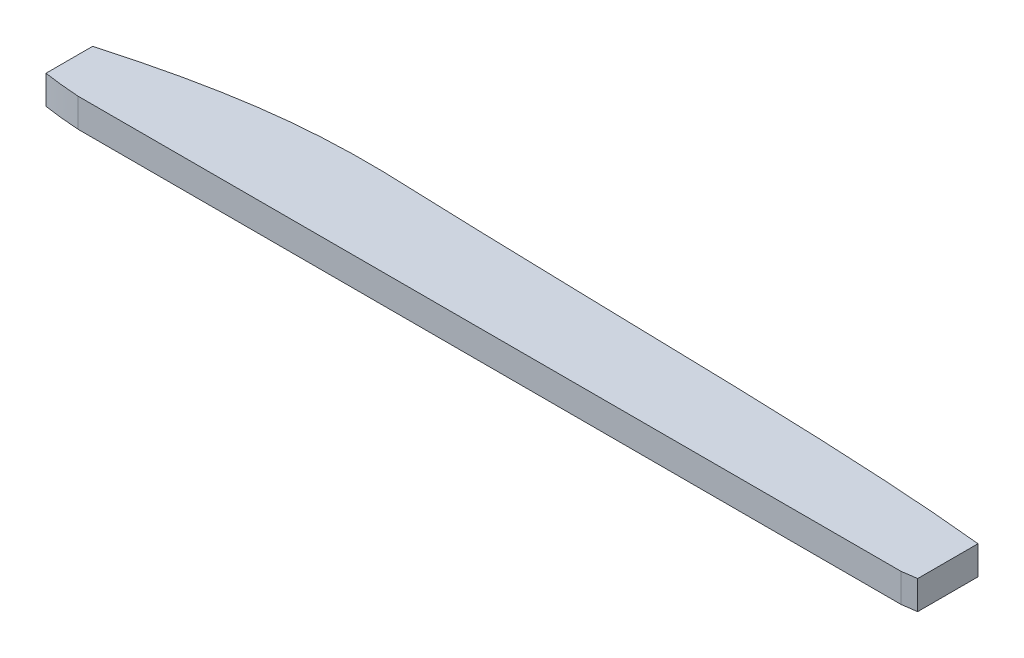
from build123d import *

# Parameters (mm, degrees)
SKETCH1_W           = 304.8
SKETCH1_H           = 76.2
BOSS_EXTRUDE1_DEPTH = 3.175
CUT_EXTRUDE3_DEPTH  = 0.254
CUT_EXTRUDE5_DEPTH  = 0.254
SKETCH2_3_OUTSIDE_W = 369.64
SKETCH2_3_OUTSIDE_H = 141.04
CUT_EXTRUDE7_DEPTH  = 315.196691105


with BuildPart() as part:
    # Sketch1 → Boss-Extrude1 (new body)
    with BuildSketch(Plane(origin=(0, 0, 0), x_dir=(1, 0, 0), z_dir=(0, 1, 0))):
        with Locations((-152.4, 38.1)):
            Rectangle(SKETCH1_W, SKETCH1_H)
    extrude(amount=BOSS_EXTRUDE1_DEPTH)

    # Sketch2 → Cut-Extrude3 (cut)
    with BuildSketch(Plane(origin=(0, 3.175, 0), x_dir=(1, 0, 0), z_dir=(0, 1, 0))):
        with BuildLine():
            Line((-304.8, 5.132354223), (-304.8, 0.390438323))
            add(Edge.make_bspline(
                [(-304.8, 0.390438323), (-303.821243343, 0.22923291), (-302.632591032, 0.100235841), (-301.136713645, 0)],
                knots=[0.767987957, 0.767987957, 0.767987957, 0.767987957, 1, 1, 1, 1], degree=3))
            Line((-301.136713645, 0), (-217.379871236, 0))
            add(Edge.make_bspline(
                [(-215.9, 0.210253502), (-216.602591478, 0.075926224), (-217.379871236, 0)],
                knots=[0.882956558, 0.882956558, 0.882956558, 1, 1, 1], degree=2))
            Line((-215.9, 0.210253502), (-215.9, 6.35))
            add(Edge.make_bspline(
                [(-304.8, 5.132354223), (-295.056068779, 7.913424716), (-284.63514545, 9.175759011), (-256.65451685, 7.910717471), (-231.983718042, 8.039058457), (-215.9, 6.35)],
                knots=[0.033341876, 0.033341876, 0.033341876, 0.033341876, 0.196819423, 0.285044024, 0.915587883, 0.915587883, 0.915587883, 0.915587883], degree=3))
        make_face()
        with BuildLine():
            Line((-304.748193138, 14.319973849), (-304.748193138, 9.578057948))
            add(Edge.make_bspline(
                [(-304.748193138, 9.578057948), (-303.76943648, 9.416852535), (-302.58078417, 9.287855466), (-301.084906782, 9.187619625)],
                knots=[0.767987957, 0.767987957, 0.767987957, 0.767987957, 1, 1, 1, 1], degree=3))
            Line((-301.084906782, 9.187619625), (-217.328064374, 9.187619625))
            add(Edge.make_bspline(
                [(-215.848193138, 9.397873128), (-216.550784616, 9.263545849), (-217.328064374, 9.187619625)],
                knots=[0.882956558, 0.882956558, 0.882956558, 1, 1, 1], degree=2))
            Line((-215.848193138, 9.397873128), (-215.848193138, 15.537619625))
            add(Edge.make_bspline(
                [(-304.748193138, 14.319973849), (-295.004261916, 17.101044341), (-284.583338588, 18.363378636), (-256.602709988, 17.098337097), (-231.93191118, 17.226678082), (-215.848193138, 15.537619625)],
                knots=[0.033341876, 0.033341876, 0.033341876, 0.033341876, 0.196819423, 0.285044024, 0.915587883, 0.915587883, 0.915587883, 0.915587883], degree=3))
        make_face()
        with BuildLine():
            Line((-304.77561062, 23.435546339), (-304.77561062, 18.693630439))
            add(Edge.make_bspline(
                [(-304.77561062, 18.693630439), (-303.796853962, 18.532425025), (-302.608201652, 18.403427957), (-301.112324264, 18.303192116)],
                knots=[0.767987957, 0.767987957, 0.767987957, 0.767987957, 1, 1, 1, 1], degree=3))
            Line((-301.112324264, 18.303192116), (-217.355481855, 18.303192116))
            add(Edge.make_bspline(
                [(-215.87561062, 18.513445618), (-216.578202097, 18.37911834), (-217.355481855, 18.303192116)],
                knots=[0.882956558, 0.882956558, 0.882956558, 1, 1, 1], degree=2))
            Line((-215.87561062, 18.513445618), (-215.87561062, 24.653192116))
            add(Edge.make_bspline(
                [(-304.77561062, 23.435546339), (-295.031679398, 26.216616832), (-284.61075607, 27.478951126), (-256.63012747, 26.213909587), (-231.959328661, 26.342250572), (-215.87561062, 24.653192116)],
                knots=[0.033341876, 0.033341876, 0.033341876, 0.033341876, 0.196819423, 0.285044024, 0.915587883, 0.915587883, 0.915587883, 0.915587883], degree=3))
        make_face()
        with BuildLine():
            Line((-304.723803757, 32.623165964), (-304.723803757, 27.881250064))
            add(Edge.make_bspline(
                [(-304.723803757, 27.881250064), (-303.7450471, 27.720044651), (-302.55639479, 27.591047582), (-301.060517402, 27.490811741)],
                knots=[0.767987957, 0.767987957, 0.767987957, 0.767987957, 1, 1, 1, 1], degree=3))
            Line((-301.060517402, 27.490811741), (-217.303674993, 27.490811741))
            add(Edge.make_bspline(
                [(-215.823803757, 27.701065244), (-216.526395235, 27.566737965), (-217.303674993, 27.490811741)],
                knots=[0.882956558, 0.882956558, 0.882956558, 1, 1, 1], degree=2))
            Line((-215.823803757, 27.701065244), (-215.823803757, 33.840811741))
            add(Edge.make_bspline(
                [(-304.723803757, 32.623165964), (-294.979872536, 35.404236457), (-284.558949208, 36.666570752), (-256.578320608, 35.401529213), (-231.907521799, 35.529870198), (-215.823803757, 33.840811741)],
                knots=[0.033341876, 0.033341876, 0.033341876, 0.033341876, 0.196819423, 0.285044024, 0.915587883, 0.915587883, 0.915587883, 0.915587883], degree=3))
        make_face()
        with BuildLine():
            Line((-304.692120731, 41.752034592), (-304.692120731, 37.010118692))
            add(Edge.make_bspline(
                [(-304.692120731, 37.010118692), (-303.713364073, 36.848913278), (-302.524711763, 36.71991621), (-301.028834375, 36.619680369)],
                knots=[0.767987957, 0.767987957, 0.767987957, 0.767987957, 1, 1, 1, 1], degree=3))
            Line((-301.028834375, 36.619680369), (-217.271991966, 36.619680369))
            add(Edge.make_bspline(
                [(-215.792120731, 36.829933871), (-216.494712209, 36.695606593), (-217.271991966, 36.619680369)],
                knots=[0.882956558, 0.882956558, 0.882956558, 1, 1, 1], degree=2))
            Line((-215.792120731, 36.829933871), (-215.792120731, 42.969680369))
            add(Edge.make_bspline(
                [(-304.692120731, 41.752034592), (-294.948189509, 44.533105085), (-284.527266181, 45.795439379), (-256.546637581, 44.53039784), (-231.875838773, 44.658738825), (-215.792120731, 42.969680369)],
                knots=[0.033341876, 0.033341876, 0.033341876, 0.033341876, 0.196819423, 0.285044024, 0.915587883, 0.915587883, 0.915587883, 0.915587883], degree=3))
        make_face()
        with BuildLine():
            Line((-304.640313869, 50.939654217), (-304.640313869, 46.197738317))
            add(Edge.make_bspline(
                [(-304.640313869, 46.197738317), (-303.661557211, 46.036532904), (-302.472904901, 45.907535835), (-300.977027513, 45.807299994)],
                knots=[0.767987957, 0.767987957, 0.767987957, 0.767987957, 1, 1, 1, 1], degree=3))
            Line((-300.977027513, 45.807299994), (-217.220185104, 45.807299994))
            add(Edge.make_bspline(
                [(-215.740313869, 46.017553497), (-216.442905346, 45.883226218), (-217.220185104, 45.807299994)],
                knots=[0.882956558, 0.882956558, 0.882956558, 1, 1, 1], degree=2))
            Line((-215.740313869, 46.017553497), (-215.740313869, 52.157299994))
            add(Edge.make_bspline(
                [(-304.640313869, 50.939654217), (-294.896382647, 53.72072471), (-284.475459319, 54.983059005), (-256.494830719, 53.718017466), (-231.82403191, 53.846358451), (-215.740313869, 52.157299994)],
                knots=[0.033341876, 0.033341876, 0.033341876, 0.033341876, 0.196819423, 0.285044024, 0.915587883, 0.915587883, 0.915587883, 0.915587883], degree=3))
        make_face()
        with BuildLine():
            Line((-304.66773135, 60.055226708), (-304.66773135, 55.313310807))
            add(Edge.make_bspline(
                [(-304.66773135, 55.313310807), (-303.688974693, 55.152105394), (-302.500322383, 55.023108326), (-301.004444995, 54.922872485)],
                knots=[0.767987957, 0.767987957, 0.767987957, 0.767987957, 1, 1, 1, 1], degree=3))
            Line((-301.004444995, 54.922872485), (-217.247602586, 54.922872485))
            add(Edge.make_bspline(
                [(-215.76773135, 55.133125987), (-216.470322828, 54.998798708), (-217.247602586, 54.922872485)],
                knots=[0.882956558, 0.882956558, 0.882956558, 1, 1, 1], degree=2))
            Line((-215.76773135, 55.133125987), (-215.76773135, 61.272872485))
            add(Edge.make_bspline(
                [(-304.66773135, 60.055226708), (-294.923800129, 62.836297201), (-284.502876801, 64.098631495), (-256.522248201, 62.833589956), (-231.851449392, 62.961930941), (-215.76773135, 61.272872485)],
                knots=[0.033341876, 0.033341876, 0.033341876, 0.033341876, 0.196819423, 0.285044024, 0.915587883, 0.915587883, 0.915587883, 0.915587883], degree=3))
        make_face()
        with BuildLine():
            Line((-304.615924488, 69.242846333), (-304.615924488, 64.500930433))
            add(Edge.make_bspline(
                [(-304.615924488, 64.500930433), (-303.637167831, 64.33972502), (-302.448515521, 64.210727951), (-300.952638133, 64.11049211)],
                knots=[0.767987957, 0.767987957, 0.767987957, 0.767987957, 1, 1, 1, 1], degree=3))
            Line((-300.952638133, 64.11049211), (-217.195795724, 64.11049211))
            add(Edge.make_bspline(
                [(-215.715924488, 64.320745612), (-216.418515966, 64.186418334), (-217.195795724, 64.11049211)],
                knots=[0.882956558, 0.882956558, 0.882956558, 1, 1, 1], degree=2))
            Line((-215.715924488, 64.320745612), (-215.715924488, 70.46049211))
            add(Edge.make_bspline(
                [(-304.615924488, 69.242846333), (-294.871993267, 72.023916826), (-284.451069938, 73.286251121), (-256.470441339, 72.021209581), (-231.79964253, 72.149550567), (-215.715924488, 70.46049211)],
                knots=[0.033341876, 0.033341876, 0.033341876, 0.033341876, 0.196819423, 0.285044024, 0.915587883, 0.915587883, 0.915587883, 0.915587883], degree=3))
        make_face()
        with BuildLine():
            Line((-215.183865707, 5.315478387), (-215.183865707, 0.573562486))
            add(Edge.make_bspline(
                [(-215.183865707, 0.573562486), (-214.20510905, 0.412357073), (-213.01645674, 0.283360005), (-211.520579352, 0.183124164)],
                knots=[0.767987957, 0.767987957, 0.767987957, 0.767987957, 1, 1, 1, 1], degree=3))
            Line((-211.520579352, 0.183124164), (-127.763736943, 0.183124164))
            add(Edge.make_bspline(
                [(-126.283865707, 0.393377666), (-126.986457185, 0.259050387), (-127.763736943, 0.183124164)],
                knots=[0.882956558, 0.882956558, 0.882956558, 1, 1, 1], degree=2))
            Line((-126.283865707, 0.393377666), (-126.283865707, 6.533124164))
            add(Edge.make_bspline(
                [(-215.183865707, 5.315478387), (-205.439934486, 8.09654888), (-195.019011157, 9.358883174), (-167.038382558, 8.093841635), (-142.367583749, 8.22218262), (-126.283865707, 6.533124164)],
                knots=[0.033341876, 0.033341876, 0.033341876, 0.033341876, 0.196819423, 0.285044024, 0.915587883, 0.915587883, 0.915587883, 0.915587883], degree=3))
        make_face()
        with BuildLine():
            Line((-215.132058845, 14.503098012), (-215.132058845, 9.761182112))
            add(Edge.make_bspline(
                [(-215.132058845, 9.761182112), (-214.153302188, 9.599976698), (-212.964649877, 9.47097963), (-211.46877249, 9.370743789)],
                knots=[0.767987957, 0.767987957, 0.767987957, 0.767987957, 1, 1, 1, 1], degree=3))
            Line((-211.46877249, 9.370743789), (-127.711930081, 9.370743789))
            add(Edge.make_bspline(
                [(-126.232058845, 9.580997291), (-126.934650323, 9.446670013), (-127.711930081, 9.370743789)],
                knots=[0.882956558, 0.882956558, 0.882956558, 1, 1, 1], degree=2))
            Line((-126.232058845, 9.580997291), (-126.232058845, 15.720743789))
            add(Edge.make_bspline(
                [(-215.132058845, 14.503098012), (-205.388127624, 17.284168505), (-194.967204295, 18.546502799), (-166.986575695, 17.28146126), (-142.315776887, 17.409802246), (-126.232058845, 15.720743789)],
                knots=[0.033341876, 0.033341876, 0.033341876, 0.033341876, 0.196819423, 0.285044024, 0.915587883, 0.915587883, 0.915587883, 0.915587883], degree=3))
        make_face()
        with BuildLine():
            Line((-215.159476327, 23.618670503), (-215.159476327, 18.876754602))
            add(Edge.make_bspline(
                [(-215.159476327, 18.876754602), (-214.180719669, 18.715549189), (-212.992067359, 18.58655212), (-211.496189971, 18.486316279)],
                knots=[0.767987957, 0.767987957, 0.767987957, 0.767987957, 1, 1, 1, 1], degree=3))
            Line((-211.496189971, 18.486316279), (-127.739347562, 18.486316279))
            add(Edge.make_bspline(
                [(-126.259476327, 18.696569782), (-126.962067804, 18.562242503), (-127.739347562, 18.486316279)],
                knots=[0.882956558, 0.882956558, 0.882956558, 1, 1, 1], degree=2))
            Line((-126.259476327, 18.696569782), (-126.259476327, 24.836316279))
            add(Edge.make_bspline(
                [(-215.159476327, 23.618670503), (-205.415545105, 26.399740996), (-194.994621777, 27.66207529), (-167.013993177, 26.397033751), (-142.343194369, 26.525374736), (-126.259476327, 24.836316279)],
                knots=[0.033341876, 0.033341876, 0.033341876, 0.033341876, 0.196819423, 0.285044024, 0.915587883, 0.915587883, 0.915587883, 0.915587883], degree=3))
        make_face()
        with BuildLine():
            Line((-215.107669465, 32.806290128), (-215.107669465, 28.064374228))
            add(Edge.make_bspline(
                [(-215.107669465, 28.064374228), (-214.128912807, 27.903168814), (-212.940260497, 27.774171746), (-211.444383109, 27.673935905)],
                knots=[0.767987957, 0.767987957, 0.767987957, 0.767987957, 1, 1, 1, 1], degree=3))
            Line((-211.444383109, 27.673935905), (-127.6875407, 27.673935905))
            add(Edge.make_bspline(
                [(-126.207669465, 27.884189407), (-126.910260942, 27.749862129), (-127.6875407, 27.673935905)],
                knots=[0.882956558, 0.882956558, 0.882956558, 1, 1, 1], degree=2))
            Line((-126.207669465, 27.884189407), (-126.207669465, 34.023935905))
            add(Edge.make_bspline(
                [(-215.107669465, 32.806290128), (-205.363738243, 35.587360621), (-194.942814915, 36.849694915), (-166.962186315, 35.584653376), (-142.291387506, 35.712994361), (-126.207669465, 34.023935905)],
                knots=[0.033341876, 0.033341876, 0.033341876, 0.033341876, 0.196819423, 0.285044024, 0.915587883, 0.915587883, 0.915587883, 0.915587883], degree=3))
        make_face()
    extrude(amount=-CUT_EXTRUDE3_DEPTH, mode=Mode.SUBTRACT)

    # Sketch3 → Cut-Extrude5 (cut)
    with BuildSketch(Plane(origin=(0, 3.175, 0), x_dir=(1, 0, 0), z_dir=(0, 1, 0))):
        with BuildLine():
            Line((-124.773731724, 0), (-73.973731724, 0))
            Line((-73.973731724, 0), (-73.973731724, 5.715))
            add(Edge.make_bspline(
                [(-124.773731724, 5.588), (-99.390849234, 12.627627449), (-73.973731724, 5.715)],
                knots=[0, 0, 0, 1, 1, 1], degree=2))
            Line((-124.773731724, 5.588), (-124.773731724, 0))
        make_face()
        with BuildLine():
            Line((-124.666073477, 9.555243731), (-73.866073477, 9.555243731))
            Line((-73.866073477, 9.555243731), (-73.866073477, 15.270243731))
            add(Edge.make_bspline(
                [(-124.666073477, 15.143243731), (-99.282006864, 21.683704535), (-73.866073477, 15.270243731)],
                knots=[0, 0, 0, 1, 1, 1], degree=2))
            Line((-124.666073477, 15.143243731), (-124.666073477, 9.555243731))
        make_face()
        with BuildLine():
            Line((-124.604715686, 19.129476511), (-73.804715686, 19.129476511))
            Line((-73.804715686, 19.129476511), (-73.804715686, 24.844476511))
            add(Edge.make_bspline(
                [(-124.604715686, 24.717476511), (-99.220649073, 31.257937315), (-73.804715686, 24.844476511)],
                knots=[0, 0, 0, 1, 1, 1], degree=2))
            Line((-124.604715686, 24.717476511), (-124.604715686, 19.129476511))
        make_face()
        with BuildLine():
            Line((-124.495240807, 28.763265862), (-73.695240807, 28.763265862))
            Line((-73.695240807, 28.763265862), (-73.695240807, 34.478265862))
            add(Edge.make_bspline(
                [(-124.495240807, 34.351265862), (-99.111174194, 40.891726665), (-73.695240807, 34.478265862)],
                knots=[0, 0, 0, 1, 1, 1], degree=2))
            Line((-124.495240807, 34.351265862), (-124.495240807, 28.763265862))
        make_face()
        with BuildLine():
            Line((-124.385765928, 38.397055212), (-73.585765928, 38.397055212))
            Line((-73.585765928, 38.397055212), (-73.585765928, 44.112055212))
            add(Edge.make_bspline(
                [(-124.385765928, 43.985055212), (-99.001699315, 50.525516016), (-73.585765928, 44.112055212)],
                knots=[0, 0, 0, 1, 1, 1], degree=2))
            Line((-124.385765928, 43.985055212), (-124.385765928, 38.397055212))
        make_face()
        with BuildLine():
            Line((-124.166816171, 49.235068231), (-73.366816171, 49.235068231))
            Line((-73.366816171, 49.235068231), (-73.366816171, 54.950068231))
            add(Edge.make_bspline(
                [(-124.166816171, 54.823068231), (-98.782749557, 61.363529035), (-73.366816171, 54.950068231)],
                knots=[0, 0, 0, 1, 1, 1], degree=2))
            Line((-124.166816171, 54.823068231), (-124.166816171, 49.235068231))
        make_face()
        with BuildLine():
            Line((-124.138868232, 59.013713621), (-73.338868232, 59.013713621))
            Line((-73.338868232, 59.013713621), (-73.338868232, 64.728713621))
            add(Edge.make_bspline(
                [(-124.138868232, 64.601713621), (-98.754801619, 71.142174425), (-73.338868232, 64.728713621)],
                knots=[0, 0, 0, 1, 1, 1], degree=2))
            Line((-124.138868232, 64.601713621), (-124.138868232, 59.013713621))
        make_face()
        with BuildLine():
            Line((-213.669393762, 38.449060159), (-162.869393762, 38.449060159))
            Line((-162.869393762, 38.449060159), (-162.869393762, 44.164060159))
            add(Edge.make_bspline(
                [(-213.669393762, 44.037060159), (-188.285327148, 50.577520962), (-162.869393762, 44.164060159)],
                knots=[0, 0, 0, 1, 1, 1], degree=2))
            Line((-213.669393762, 44.037060159), (-213.669393762, 38.449060159))
        make_face()
        with BuildLine():
            Line((-213.513008565, 49.239638781), (-162.713008565, 49.239638781))
            Line((-162.713008565, 49.239638781), (-162.713008565, 54.954638781))
            add(Edge.make_bspline(
                [(-213.513008565, 54.827638781), (-188.128941951, 61.368099585), (-162.713008565, 54.954638781)],
                knots=[0, 0, 0, 1, 1, 1], degree=2))
            Line((-213.513008565, 54.827638781), (-213.513008565, 49.239638781))
        make_face()
        with BuildLine():
            Line((-213.20023817, 60.030217404), (-162.40023817, 60.030217404))
            Line((-162.40023817, 60.030217404), (-162.40023817, 65.745217404))
            add(Edge.make_bspline(
                [(-213.20023817, 65.618217404), (-187.816171556, 72.158678208), (-162.40023817, 65.745217404)],
                knots=[0, 0, 0, 1, 1, 1], degree=2))
            Line((-213.20023817, 65.618217404), (-213.20023817, 60.030217404))
        make_face()
        Polygon((0, 76.2), (-31.75, 76.2), (-63.5, 0), (0, 0), align=None)
    extrude(amount=-CUT_EXTRUDE5_DEPTH, mode=Mode.SUBTRACT)

    # Sketch2_3 outside → Cut-Extrude7 (cut, through all)
    with BuildSketch(Plane(origin=(0, 3.175, 0), x_dir=(1, 0, 0), z_dir=(0, 1, 0))):
        with Locations((-152.4, 38.1)):
            Rectangle(SKETCH2_3_OUTSIDE_W, SKETCH2_3_OUTSIDE_H)
        with BuildLine():
            add(Edge.make_bspline(
                [(-304.615924488, 69.242846333), (-294.871993267, 72.023916826), (-284.451069938, 73.286251121), (-256.470441339, 72.021209581), (-231.79964253, 72.149550567), (-215.715924488, 70.46049211)],
                knots=[0.033341876, 0.033341876, 0.033341876, 0.033341876, 0.196819423, 0.285044024, 0.915587883, 0.915587883, 0.915587883, 0.915587883], degree=3))
            Line((-304.615924488, 69.242846333), (-304.615924488, 64.500930433))
            add(Edge.make_bspline(
                [(-304.615924488, 64.500930433), (-303.637167831, 64.33972502), (-302.448515521, 64.210727951), (-300.952638133, 64.11049211)],
                knots=[0.767987957, 0.767987957, 0.767987957, 0.767987957, 1, 1, 1, 1], degree=3))
            Line((-300.952638133, 64.11049211), (-217.195795724, 64.11049211))
            add(Edge.make_bspline(
                [(-215.715924488, 64.320745612), (-216.418515966, 64.186418334), (-217.195795724, 64.11049211)],
                knots=[0.882956558, 0.882956558, 0.882956558, 1, 1, 1], degree=2))
            Line((-215.715924488, 64.320745612), (-215.715924488, 70.46049211))
        make_face(mode=Mode.SUBTRACT)
    extrude(amount=-CUT_EXTRUDE7_DEPTH, mode=Mode.SUBTRACT)


solid = part.part
